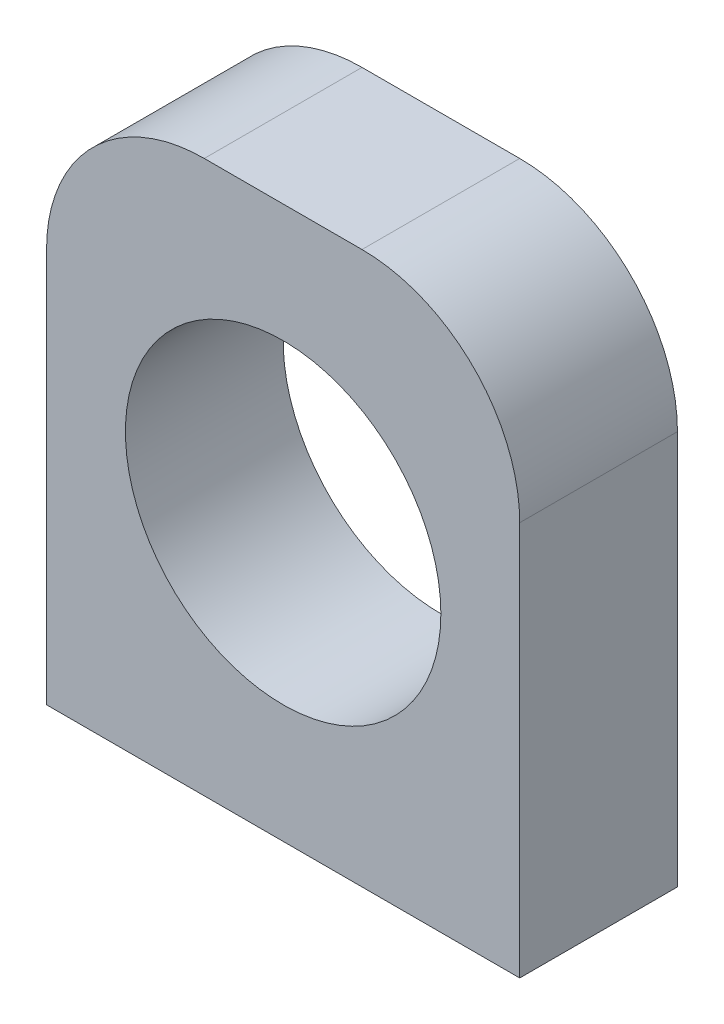
from build123d import *

# Parameters (mm, degrees)
SKETCH1_R                  = 25.4
BOSS_EXTRUDE1_DEPTH        = 12.7
F_10_32_TAPPED_HOLE1_D     = 4.0386
F_10_32_TAPPED_HOLE1_DEPTH = 12.02944
F_10_32_TAPPED_HOLE1_TIP   = 1.213317848


with BuildPart() as part:
    # Sketch1 → Boss-Extrude1 (new body, symmetric)
    with BuildSketch(Plane.XY):
        with BuildLine():
            Line((38.1, -44.45), (-38.1, -44.45))
            Line((-38.1, -44.45), (-38.1, 19.05))
            ThreePointArc((-38.1, 19.05), (-30.660512242, 37.010512242), (-12.7, 44.45))
            Line((-12.7, 44.45), (12.7, 44.45))
            ThreePointArc((12.7, 44.45), (30.660512242, 37.010512242), (38.1, 19.05))
            Line((38.1, 19.05), (38.1, -44.45))
        make_face()
        Circle(SKETCH1_R, mode=Mode.SUBTRACT)
    extrude(amount=BOSS_EXTRUDE1_DEPTH, both=True)

    # #10-32 Tapped Hole1
    with Locations(Plane(origin=(0, -44.45, 0), x_dir=(-1, 0, 0), z_dir=(0, -1, 0))):
        with Locations((19.05, -7.9375), (-19.05, -7.9375), (-19.05, 7.9375), (19.05, 7.9375)):
            Hole(F_10_32_TAPPED_HOLE1_D / 2, depth=F_10_32_TAPPED_HOLE1_DEPTH)
            with Locations((0, 0, -(F_10_32_TAPPED_HOLE1_DEPTH + F_10_32_TAPPED_HOLE1_TIP / 2))):  # 118° drill point
                Cone(0, F_10_32_TAPPED_HOLE1_D / 2, F_10_32_TAPPED_HOLE1_TIP, mode=Mode.SUBTRACT)


solid = part.part
